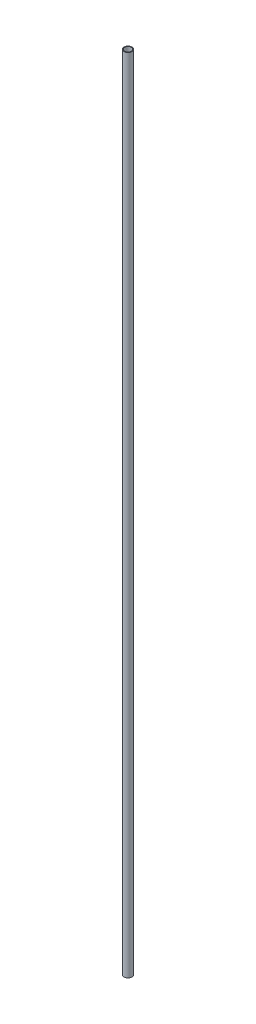
from build123d import *

# Parameters (mm, degrees)
SKETCH1_R           = 38.1
SKETCH1_R_2         = 31.75
BOSS_EXTRUDE1_DEPTH = 3810


with BuildPart() as part:
    # Sketch1 → Boss-Extrude1 (new body, symmetric)
    with BuildSketch(Plane(origin=(0, 0, 0), x_dir=(1, 0, 0), z_dir=(0, 1, 0))):
        Circle(SKETCH1_R)
        Circle(SKETCH1_R_2, mode=Mode.SUBTRACT)
    extrude(amount=BOSS_EXTRUDE1_DEPTH, both=True)


solid = part.part
